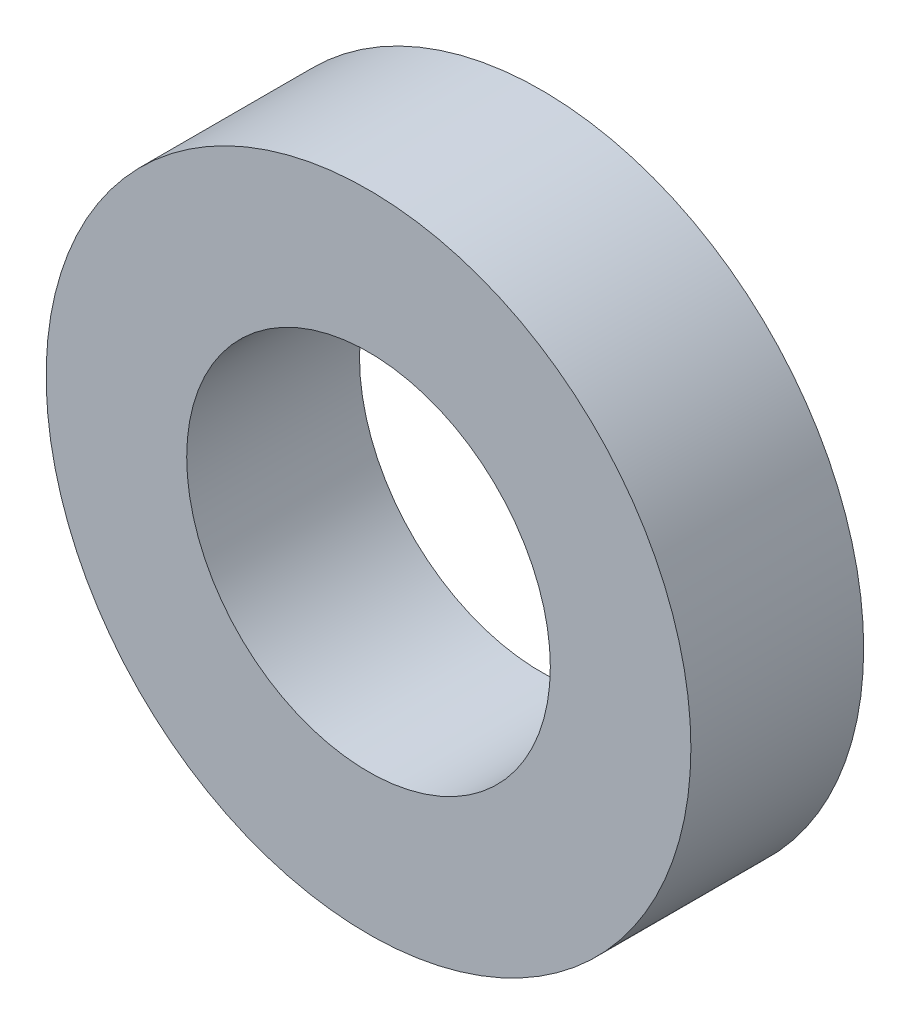
from build123d import *

# Parameters (mm, degrees)
SKETCH1_R      = 3.175
SKETCH1_R_2    = 1.7907
EXTRUDE1_DEPTH = 1.7018


with BuildPart() as part:
    # Sketch1 → Extrude1 (new body)
    with BuildSketch(Plane.XY):
        Circle(SKETCH1_R)
        Circle(SKETCH1_R_2, mode=Mode.SUBTRACT)
    extrude(amount=-EXTRUDE1_DEPTH)


solid = part.part
